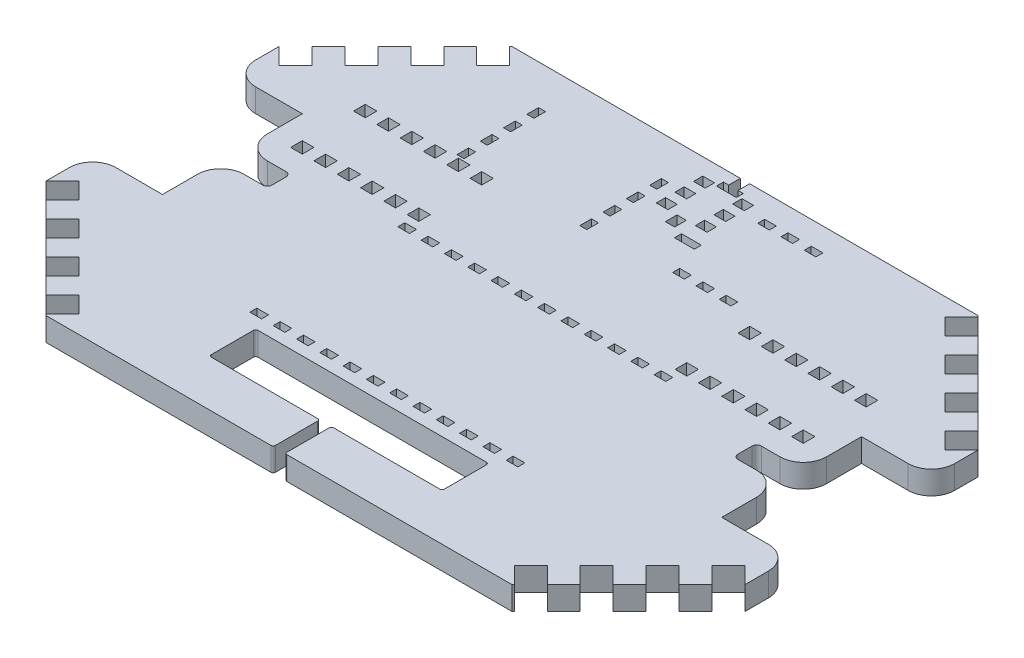
from build123d import *

# Parameters (mm, degrees)
ESQUISSE1_W                = 300
ESQUISSE1_H                = 200
BOSS_EXTRU_1_DEPTH         = 10
ENL_V_MAT_EXTRU_1_DEPTH    = 10
ENL_V_MAT_EXTRU_11_DEPTH   = 10
R_P_TITION_LIN_AIRE2_COUNT = 4
R_P_TITION_LIN_AIRE2_PITCH = 20
SYM_TRIE2_COPY_1_DEPTH     = 10
SYM_TRIE2_COPY_2_DEPTH     = 10
SYM_TRIE2_COPY_3_DEPTH     = 10
SYM_TRIE3_COPY_1_DEPTH     = 10
SYM_TRIE3_COPY_2_DEPTH     = 10
SYM_TRIE3_COPY_3_DEPTH     = 10
SYM_TRIE3_COPY_4_DEPTH     = 10
SYM_TRIE3_COPY_5_DEPTH     = 10
SYM_TRIE3_COPY_6_DEPTH     = 10
SYM_TRIE3_COPY_7_DEPTH     = 10
ESQUISSE14_W               = 30
ESQUISSE14_H               = 15
ENL_V_MAT_EXTRU_13_DEPTH   = 10
ESQUISSE15_W               = 5
ESQUISSE15_H               = 5
ENL_V_MAT_EXTRU_14_DEPTH   = 10
R_P_TITION_LIN_AIRE3_COUNT = 3
R_P_TITION_LIN_AIRE3_PITCH = 10
ESQUISSE31_W               = 5
ESQUISSE31_H               = 4
ESQUISSE31_W_2             = 4
ESQUISSE31_H_2             = 5
ENL_V_MAT_EXTRU_29_DEPTH   = 10
ESQUISSE32_W               = 30
ESQUISSE32_H               = 60
ENL_V_MAT_EXTRU_30_DEPTH   = 10
ESQUISSE33_W               = 5
ESQUISSE33_H               = 5
ENL_V_MAT_EXTRU_31_DEPTH   = 10
ESQUISSE34_W               = 100
ESQUISSE34_H               = 20
ENL_V_MAT_EXTRU_33_DEPTH   = 10
ESQUISSE35_W               = 5
ESQUISSE35_H               = 20
ENL_V_MAT_EXTRU_34_DEPTH   = 10
CONG_1_R                   = 1
ESQUISSE36_W               = 5
ESQUISSE36_H               = 3
ENL_V_MAT_EXTRU_35_DEPTH   = 10
ESQUISSE37_W               = 8.5
ESQUISSE37_H               = 3
ENL_V_MAT_EXTRU_36_DEPTH   = 10
ESQUISSE39_W               = 8.5
ESQUISSE39_H               = 3
ENL_V_MAT_EXTRU_37_DEPTH   = 10
ESQUISSE40_W               = 5
ESQUISSE40_H               = 3
ENL_V_MAT_EXTRU_39_DEPTH   = 10
ESQUISSE41_W               = 3
ESQUISSE41_H               = 5
ENL_V_MAT_EXTRU_40_DEPTH   = 10
ESQUISSE42_W               = 20
ESQUISSE42_H               = 10
ENL_V_MAT_EXTRU_41_DEPTH   = 10
CONG_2_R                   = 10
CONG_3_R                   = 2
CONG_4_R                   = 10


with BuildPart() as part:
    # Esquisse1 → Boss.-Extru.1 (new body)
    with BuildSketch(Plane(origin=(0, 0, 0), x_dir=(1, 0, 0), z_dir=(0, 1, 0))):
        Rectangle(ESQUISSE1_W, ESQUISSE1_H)
    extrude(amount=BOSS_EXTRU_1_DEPTH)

    # Esquisse2 → Enlèv. mat.-Extru.1 (cut)
    with BuildSketch(Plane(origin=(0, 10, 0), x_dir=(1, 0, 0), z_dir=(0, 1, 0))):
        Polygon((-100, 100), (-150, 50), (-150, 100), align=None)
        Polygon((150, 100), (150, 50), (100, 100), align=None)
        Polygon((150, -100), (150, -50), (100, -100), align=None)
        Polygon((-100, -100), (-150, -100), (-150, -50), align=None)
    extrude(amount=-ENL_V_MAT_EXTRU_1_DEPTH, mode=Mode.SUBTRACT)

    # Esquisse12 → Enlèv. mat.-Extru.11 (cut)
    with BuildSketch(Plane(origin=(0, 10, 0), x_dir=(1, 0, 0), z_dir=(0, 1, 0))):
        Polygon((-150, 50), (-142.928932188, 57.071067812), (-135.857864376, 50), (-142.928932188, 42.928932188), align=None)
    enl_v_mat_extru_11 = extrude(amount=-ENL_V_MAT_EXTRU_11_DEPTH, mode=Mode.SUBTRACT)

    # Répétition linéaire2: Enlèv. mat.-Extru.11 ×4
    with Locations(*[Vector(0.707106781, 0, -0.707106781) * (i * R_P_TITION_LIN_AIRE2_PITCH) for i in range(1, R_P_TITION_LIN_AIRE2_COUNT)]):
        add(enl_v_mat_extru_11, mode=Mode.SUBTRACT)

    # Symétrie2: Enlèv. mat.-Extru.11 across plane
    add(enl_v_mat_extru_11.mirror(Plane.XY), mode=Mode.SUBTRACT)

    # Symétrie2 copy 1 sketch → Symétrie2 copy 1 (cut)
    with BuildSketch(Plane(origin=(14.142135624, 10, 14.142135624), x_dir=(1, 0, 0), z_dir=(0, 1, 0))):
        Polygon((-150, -50), (-142.928932188, -57.071067812), (-135.857864376, -50), (-142.928932188, -42.928932188), align=None)
    extrude(amount=-SYM_TRIE2_COPY_1_DEPTH, mode=Mode.SUBTRACT)

    # Symétrie2 copy 2 sketch → Symétrie2 copy 2 (cut)
    with BuildSketch(Plane(origin=(28.284271247, 10, 28.284271247), x_dir=(1, 0, 0), z_dir=(0, 1, 0))):
        Polygon((-150, -50), (-142.928932188, -57.071067812), (-135.857864376, -50), (-142.928932188, -42.928932188), align=None)
    extrude(amount=-SYM_TRIE2_COPY_2_DEPTH, mode=Mode.SUBTRACT)

    # Symétrie2 copy 3 sketch → Symétrie2 copy 3 (cut)
    with BuildSketch(Plane(origin=(42.426406871, 10, 42.426406871), x_dir=(1, 0, 0), z_dir=(0, 1, 0))):
        Polygon((-150, -50), (-142.928932188, -57.071067812), (-135.857864376, -50), (-142.928932188, -42.928932188), align=None)
    extrude(amount=-SYM_TRIE2_COPY_3_DEPTH, mode=Mode.SUBTRACT)

    # Symétrie3: Enlèv. mat.-Extru.11 across plane
    add(enl_v_mat_extru_11.mirror(Plane(origin=(0, 0, 0), x_dir=(0, 0, 1), z_dir=(1, 0, 0))), mode=Mode.SUBTRACT)

    # Symétrie3 copy 1 sketch → Symétrie3 copy 1 (cut)
    with BuildSketch(Plane(origin=(0, 10, 0), x_dir=(-1, 0, 0), z_dir=(0, 1, 0))):
        Polygon((-150, 50), (-142.928932188, 57.071067812), (-135.857864376, 50), (-142.928932188, 42.928932188), align=None)
    extrude(amount=-SYM_TRIE3_COPY_1_DEPTH, mode=Mode.SUBTRACT)

    # Symétrie3 copy 2 sketch → Symétrie3 copy 2 (cut)
    with BuildSketch(Plane(origin=(-14.142135624, 10, 14.142135624), x_dir=(-1, 0, 0), z_dir=(0, 1, 0))):
        Polygon((-150, 50), (-142.928932188, 57.071067812), (-135.857864376, 50), (-142.928932188, 42.928932188), align=None)
    extrude(amount=-SYM_TRIE3_COPY_2_DEPTH, mode=Mode.SUBTRACT)

    # Symétrie3 copy 3 sketch → Symétrie3 copy 3 (cut)
    with BuildSketch(Plane(origin=(-28.284271247, 10, 28.284271247), x_dir=(-1, 0, 0), z_dir=(0, 1, 0))):
        Polygon((-150, 50), (-142.928932188, 57.071067812), (-135.857864376, 50), (-142.928932188, 42.928932188), align=None)
    extrude(amount=-SYM_TRIE3_COPY_3_DEPTH, mode=Mode.SUBTRACT)

    # Symétrie3 copy 4 sketch → Symétrie3 copy 4 (cut)
    with BuildSketch(Plane(origin=(-42.426406871, 10, 42.426406871), x_dir=(-1, 0, 0), z_dir=(0, 1, 0))):
        Polygon((-150, 50), (-142.928932188, 57.071067812), (-135.857864376, 50), (-142.928932188, 42.928932188), align=None)
    extrude(amount=-SYM_TRIE3_COPY_4_DEPTH, mode=Mode.SUBTRACT)

    # Symétrie3 copy 5 sketch → Symétrie3 copy 5 (cut)
    with BuildSketch(Plane(origin=(-14.142135624, 10, -14.142135624), x_dir=(-1, 0, 0), z_dir=(0, 1, 0))):
        Polygon((-150, -50), (-142.928932188, -57.071067812), (-135.857864376, -50), (-142.928932188, -42.928932188), align=None)
    extrude(amount=-SYM_TRIE3_COPY_5_DEPTH, mode=Mode.SUBTRACT)

    # Symétrie3 copy 6 sketch → Symétrie3 copy 6 (cut)
    with BuildSketch(Plane(origin=(-28.284271247, 10, -28.284271247), x_dir=(-1, 0, 0), z_dir=(0, 1, 0))):
        Polygon((-150, -50), (-142.928932188, -57.071067812), (-135.857864376, -50), (-142.928932188, -42.928932188), align=None)
    extrude(amount=-SYM_TRIE3_COPY_6_DEPTH, mode=Mode.SUBTRACT)

    # Symétrie3 copy 7 sketch → Symétrie3 copy 7 (cut)
    with BuildSketch(Plane(origin=(-42.426406871, 10, -42.426406871), x_dir=(-1, 0, 0), z_dir=(0, 1, 0))):
        Polygon((-150, -50), (-142.928932188, -57.071067812), (-135.857864376, -50), (-142.928932188, -42.928932188), align=None)
    extrude(amount=-SYM_TRIE3_COPY_7_DEPTH, mode=Mode.SUBTRACT)

    # Esquisse14 → Enlèv. mat.-Extru.13 (cut)
    with BuildSketch(Plane(origin=(0, 10, 0), x_dir=(1, 0, 0), z_dir=(0, 1, 0))):
        with Locations((-135, 0)):
            Rectangle(ESQUISSE14_W, ESQUISSE14_H)
    extrude(amount=-ENL_V_MAT_EXTRU_13_DEPTH, mode=Mode.SUBTRACT)

    # Esquisse15 → Enlèv. mat.-Extru.14 (cut)
    with BuildSketch(Plane(origin=(0, 10, 0), x_dir=(1, 0, 0), z_dir=(0, 1, 0))):
        with Locations((-147.5, -15.4)):
            Rectangle(ESQUISSE15_W, ESQUISSE15_H)
    enl_v_mat_extru_14 = extrude(amount=-ENL_V_MAT_EXTRU_14_DEPTH, mode=Mode.SUBTRACT)

    # Répétition linéaire3: Enlèv. mat.-Extru.14 ×3
    with Locations(*[(i * R_P_TITION_LIN_AIRE3_PITCH, 0, 0) for i in range(1, R_P_TITION_LIN_AIRE3_COUNT)]):
        add(enl_v_mat_extru_14, mode=Mode.SUBTRACT)

    # Esquisse31 → Enlèv. mat.-Extru.29 (cut)
    with BuildSketch(Plane.XZ):
        with Locations((8.4, -74.8)):
            Rectangle(ESQUISSE31_W, ESQUISSE31_H)
        with Locations((8.4, -82.8)):
            Rectangle(ESQUISSE31_W, ESQUISSE31_H)
        with Locations((8.4, -90.8)):
            Rectangle(ESQUISSE31_W, ESQUISSE31_H)
        with Locations((-8.4, -90.8)):
            Rectangle(ESQUISSE31_W, ESQUISSE31_H)
        with Locations((-8.4, -82.8)):
            Rectangle(ESQUISSE31_W, ESQUISSE31_H)
        with Locations((-8.4, -74.8)):
            Rectangle(ESQUISSE31_W, ESQUISSE31_H)
        with Locations((0, -70.3)):
            Rectangle(ESQUISSE31_W_2, ESQUISSE31_H_2)
        with Locations((0, -97.5)):
            Rectangle(ESQUISSE31_W_2, ESQUISSE31_H_2)
    extrude(amount=-ENL_V_MAT_EXTRU_29_DEPTH, mode=Mode.SUBTRACT)

    # Esquisse32 → Enlèv. mat.-Extru.30 (cut)
    with BuildSketch(Plane.XZ):
        with Locations((135, 0)):
            Rectangle(ESQUISSE32_W, ESQUISSE32_H)
        with Locations((-135, 0)):
            Rectangle(ESQUISSE32_W, ESQUISSE32_H)
    extrude(amount=-ENL_V_MAT_EXTRU_30_DEPTH, mode=Mode.SUBTRACT)

    # Esquisse33 → Enlèv. mat.-Extru.31 (cut)
    with BuildSketch(Plane.XZ):
        with Locations((67.5, -44.5)):
            Rectangle(ESQUISSE33_W, ESQUISSE33_H)
        with Locations((107.5, -17.5)):
            Rectangle(ESQUISSE33_W, ESQUISSE33_H)
        with Locations((97.5, -17.5)):
            Rectangle(ESQUISSE33_W, ESQUISSE33_H)
        with Locations((87.5, -17.5)):
            Rectangle(ESQUISSE33_W, ESQUISSE33_H)
        with Locations((77.5, -17.5)):
            Rectangle(ESQUISSE33_W, ESQUISSE33_H)
        with Locations((97.5, -44.5)):
            Rectangle(ESQUISSE33_W, ESQUISSE33_H)
        with Locations((87.5, -44.5)):
            Rectangle(ESQUISSE33_W, ESQUISSE33_H)
        with Locations((77.5, -44.5)):
            Rectangle(ESQUISSE33_W, ESQUISSE33_H)
        with Locations((107.5, -44.5)):
            Rectangle(ESQUISSE33_W, ESQUISSE33_H)
        with Locations((-107.5, -44.5)):
            Rectangle(ESQUISSE33_W, ESQUISSE33_H)
        with Locations((-77.5, -44.5)):
            Rectangle(ESQUISSE33_W, ESQUISSE33_H)
        with Locations((-87.5, -44.5)):
            Rectangle(ESQUISSE33_W, ESQUISSE33_H)
        with Locations((-97.5, -44.5)):
            Rectangle(ESQUISSE33_W, ESQUISSE33_H)
        with Locations((-77.5, -17.5)):
            Rectangle(ESQUISSE33_W, ESQUISSE33_H)
        with Locations((-87.5, -17.5)):
            Rectangle(ESQUISSE33_W, ESQUISSE33_H)
        with Locations((-97.5, -17.5)):
            Rectangle(ESQUISSE33_W, ESQUISSE33_H)
        with Locations((-107.5, -17.5)):
            Rectangle(ESQUISSE33_W, ESQUISSE33_H)
        with Locations((57.5, -44.5)):
            Rectangle(ESQUISSE33_W, ESQUISSE33_H)
        with Locations((67.5, -17.5)):
            Rectangle(ESQUISSE33_W, ESQUISSE33_H)
        with Locations((57.5, -17.5)):
            Rectangle(ESQUISSE33_W, ESQUISSE33_H)
        with Locations((-67.5, -44.5)):
            Rectangle(ESQUISSE33_W, ESQUISSE33_H)
        with Locations((-67.5, -17.5)):
            Rectangle(ESQUISSE33_W, ESQUISSE33_H)
        with Locations((-57.5, -44.5)):
            Rectangle(ESQUISSE33_W, ESQUISSE33_H)
        with Locations((-57.5, -17.5)):
            Rectangle(ESQUISSE33_W, ESQUISSE33_H)
    extrude(amount=-ENL_V_MAT_EXTRU_31_DEPTH, mode=Mode.SUBTRACT)

    # Esquisse34 → Enlèv. mat.-Extru.33 (cut)
    with BuildSketch(Plane.XZ):
        with Locations((0, 70)):
            Rectangle(ESQUISSE34_W, ESQUISSE34_H)
    extrude(amount=-ENL_V_MAT_EXTRU_33_DEPTH, mode=Mode.SUBTRACT)

    # Esquisse35 → Enlèv. mat.-Extru.34 (cut)
    with BuildSketch(Plane(origin=(0, 10, 0), x_dir=(1, 0, 0), z_dir=(0, 1, 0))):
        with Locations((0, -90)):
            Rectangle(ESQUISSE35_W, ESQUISSE35_H)
    extrude(amount=-ENL_V_MAT_EXTRU_34_DEPTH, mode=Mode.SUBTRACT)

    # Congé1
    cong_1_edges = [part.edges().sort_by_distance(p)[0] for p in [
        (50, 5, 60),
        (50, 5, 80),
        (-50, 5, 80),
        (-50, 5, 60),
        (-2.5, 5, 100),
        (-2.5, 5, 80),
        (2.5, 5, 80),
        (2.5, 5, 100),
    ]]
    fillet(cong_1_edges, radius=CONG_1_R)

    # Esquisse36 → Enlèv. mat.-Extru.35 (cut)
    with BuildSketch(Plane(origin=(0, 10, 0), x_dir=(1, 0, 0), z_dir=(0, 1, 0))):
        with Locations((40.931457505, 88.5)):
            Rectangle(ESQUISSE36_W, ESQUISSE36_H)
        with Locations((30.931457505, 88.5)):
            Rectangle(ESQUISSE36_W, ESQUISSE36_H)
        with Locations((20.931457505, 88.5)):
            Rectangle(ESQUISSE36_W, ESQUISSE36_H)
        with Locations((30.931457505, 52)):
            Rectangle(ESQUISSE36_W, ESQUISSE36_H)
        with Locations((40.931457505, 52)):
            Rectangle(ESQUISSE36_W, ESQUISSE36_H)
        with Locations((20.931457505, 52)):
            Rectangle(ESQUISSE36_W, ESQUISSE36_H)
    extrude(amount=-ENL_V_MAT_EXTRU_35_DEPTH, mode=Mode.SUBTRACT)

    # Esquisse37 → Enlèv. mat.-Extru.36 (cut)
    with BuildSketch(Plane(origin=(0, 10, 0), x_dir=(1, 0, 0), z_dir=(0, 1, 0))):
        with Locations((10.207351288, 65.290148118)):
            Rectangle(ESQUISSE37_W, ESQUISSE37_H)
    extrude(amount=-ENL_V_MAT_EXTRU_36_DEPTH, mode=Mode.SUBTRACT)

    # Esquisse39 → Enlèv. mat.-Extru.37 (cut)
    with BuildSketch(Plane(origin=(0, 10, 0), x_dir=(1, 0, 0), z_dir=(0, 1, 0))):
        with Locations((0, 93.5)):
            Rectangle(ESQUISSE39_W, ESQUISSE39_H)
    extrude(amount=-ENL_V_MAT_EXTRU_37_DEPTH, mode=Mode.SUBTRACT)

    # Esquisse40 → Enlèv. mat.-Extru.39 (cut)
    with BuildSketch(Plane(origin=(0, 10, 0), x_dir=(1, 0, 0), z_dir=(0, 1, 0))):
        with Locations((55, -53.5)):
            Rectangle(ESQUISSE40_W, ESQUISSE40_H)
        with Locations((45, -53.5)):
            Rectangle(ESQUISSE40_W, ESQUISSE40_H)
        with Locations((35, -53.5)):
            Rectangle(ESQUISSE40_W, ESQUISSE40_H)
        with Locations((25, -53.5)):
            Rectangle(ESQUISSE40_W, ESQUISSE40_H)
        with Locations((15, -53.5)):
            Rectangle(ESQUISSE40_W, ESQUISSE40_H)
        with Locations((5, -53.5)):
            Rectangle(ESQUISSE40_W, ESQUISSE40_H)
        with Locations((-5, -53.5)):
            Rectangle(ESQUISSE40_W, ESQUISSE40_H)
        with Locations((-15, -53.5)):
            Rectangle(ESQUISSE40_W, ESQUISSE40_H)
        with Locations((-25, -53.5)):
            Rectangle(ESQUISSE40_W, ESQUISSE40_H)
        with Locations((-35, -53.5)):
            Rectangle(ESQUISSE40_W, ESQUISSE40_H)
        with Locations((-45, -53.5)):
            Rectangle(ESQUISSE40_W, ESQUISSE40_H)
        with Locations((-55, -53.5)):
            Rectangle(ESQUISSE40_W, ESQUISSE40_H)
        with Locations((-55, 10)):
            Rectangle(ESQUISSE40_W, ESQUISSE40_H)
        with Locations((-45, 10)):
            Rectangle(ESQUISSE40_W, ESQUISSE40_H)
        with Locations((-35, 10)):
            Rectangle(ESQUISSE40_W, ESQUISSE40_H)
        with Locations((-25, 10)):
            Rectangle(ESQUISSE40_W, ESQUISSE40_H)
        with Locations((-15, 10)):
            Rectangle(ESQUISSE40_W, ESQUISSE40_H)
        with Locations((-5, 10)):
            Rectangle(ESQUISSE40_W, ESQUISSE40_H)
        with Locations((5, 10)):
            Rectangle(ESQUISSE40_W, ESQUISSE40_H)
        with Locations((15, 10)):
            Rectangle(ESQUISSE40_W, ESQUISSE40_H)
        with Locations((25, 10)):
            Rectangle(ESQUISSE40_W, ESQUISSE40_H)
        with Locations((35, 10)):
            Rectangle(ESQUISSE40_W, ESQUISSE40_H)
        with Locations((45, 10)):
            Rectangle(ESQUISSE40_W, ESQUISSE40_H)
        with Locations((55, 10)):
            Rectangle(ESQUISSE40_W, ESQUISSE40_H)
    extrude(amount=-ENL_V_MAT_EXTRU_39_DEPTH, mode=Mode.SUBTRACT)

    # Esquisse41 → Enlèv. mat.-Extru.40 (cut)
    with BuildSketch(Plane(origin=(0, 10, 0), x_dir=(1, 0, 0), z_dir=(0, 1, 0))):
        with Locations((-17.4, 80.5)):
            Rectangle(ESQUISSE41_W, ESQUISSE41_H)
        with Locations((-17.4, 70.5)):
            Rectangle(ESQUISSE41_W, ESQUISSE41_H)
        with Locations((-17.4, 60.5)):
            Rectangle(ESQUISSE41_W, ESQUISSE41_H)
        with Locations((-17.4, 50.5)):
            Rectangle(ESQUISSE41_W, ESQUISSE41_H)
        with Locations((-70.1, 50.5)):
            Rectangle(ESQUISSE41_W, ESQUISSE41_H)
        with Locations((-70.1, 60.5)):
            Rectangle(ESQUISSE41_W, ESQUISSE41_H)
        with Locations((-70.1, 70.5)):
            Rectangle(ESQUISSE41_W, ESQUISSE41_H)
        with Locations((-70.1, 80.5)):
            Rectangle(ESQUISSE41_W, ESQUISSE41_H)
    extrude(amount=-ENL_V_MAT_EXTRU_40_DEPTH, mode=Mode.SUBTRACT)

    # Esquisse42 → Enlèv. mat.-Extru.41 (cut)
    with BuildSketch(Plane(origin=(0, 10, 0), x_dir=(1, 0, 0), z_dir=(0, 1, 0))):
        with Locations((110, 0)):
            Rectangle(ESQUISSE42_W, ESQUISSE42_H)
        with Locations((-110, 0)):
            Rectangle(ESQUISSE42_W, ESQUISSE42_H)
    extrude(amount=-ENL_V_MAT_EXTRU_41_DEPTH, mode=Mode.SUBTRACT)

    # Congé2
    cong_2_edges = [part.edges().sort_by_distance(p)[0] for p in [
        (120, 5, -5),
        (120, 5, 5),
        (-120, 5, -5),
        (-120, 5, 5),
    ]]
    fillet(cong_2_edges, radius=CONG_2_R)

    # Congé3
    cong_3_edges = [part.edges().sort_by_distance(p)[0] for p in [
        (100, 5, 5),
        (100, 5, -5),
        (-100, 5, -5),
        (-100, 5, 5),
    ]]
    fillet(cong_3_edges, radius=CONG_3_R)

    # Congé4
    cong_4_edges = [part.edges().sort_by_distance(p)[0] for p in [
        (150, 5, -30),
        (150, 5, 30),
        (-150, 5, -30),
        (-150, 5, 30),
    ]]
    fillet(cong_4_edges, radius=CONG_4_R)


solid = part.part
